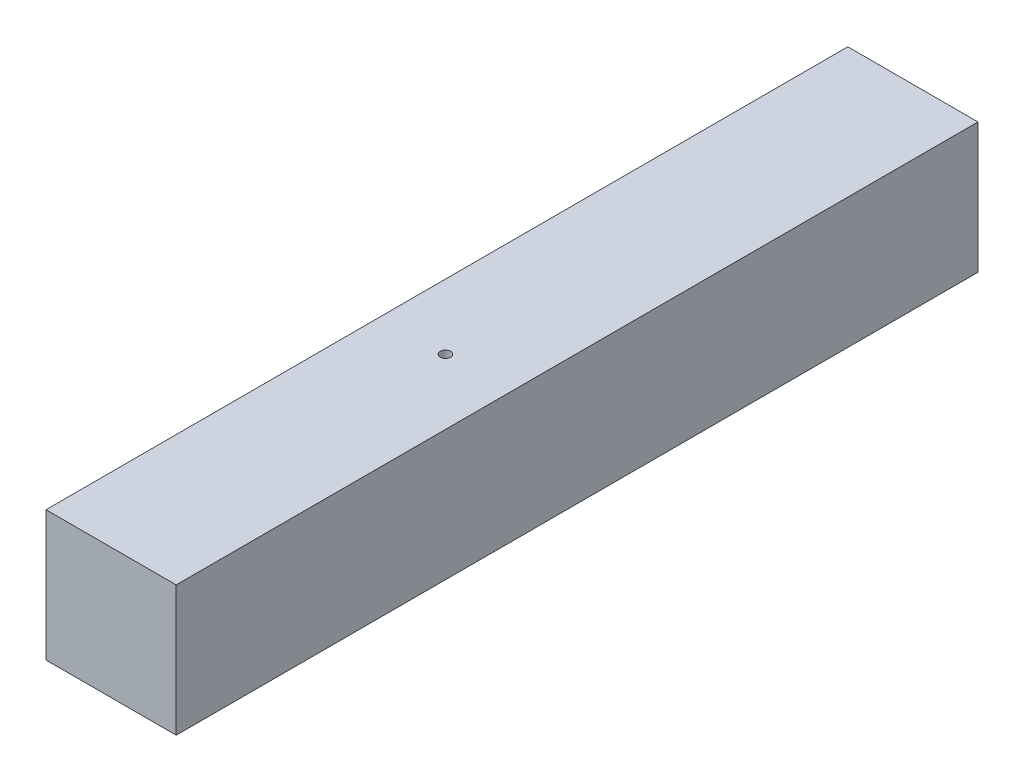
from build123d import *

# Parameters (mm, degrees)
ESQUISSE1_W             = 44
ESQUISSE1_H             = 44
BOSS_EXTRU_1_DEPTH      = 271
ESQUISSE2_R             = 1.75
ENL_V_MAT_EXTRU_1_DEPTH = 44
ESQUISSE3_R             = 1.75
ENL_V_MAT_EXTRU_2_DEPTH = 60


with BuildPart() as part:
    # Esquisse1 → Boss.-Extru.1 (new body)
    with BuildSketch(Plane.XY):
        Rectangle(ESQUISSE1_W, ESQUISSE1_H)
    extrude(amount=BOSS_EXTRU_1_DEPTH)

    # Esquisse2 → Enlèv. mat.-Extru.1 (cut)
    with BuildSketch(Plane.XZ.offset(22)):
        with Locations((0, 158)):
            Circle(ESQUISSE2_R)
    extrude(amount=-ENL_V_MAT_EXTRU_1_DEPTH, mode=Mode.SUBTRACT)

    # Esquisse3 → Enlèv. mat.-Extru.2 (cut)
    with BuildSketch(Plane(origin=(0, 0, 0), x_dir=(-1, 0, 0), z_dir=(0, 0, -1))):
        Circle(ESQUISSE3_R)
    extrude(amount=-ENL_V_MAT_EXTRU_2_DEPTH, mode=Mode.SUBTRACT)


solid = part.part
